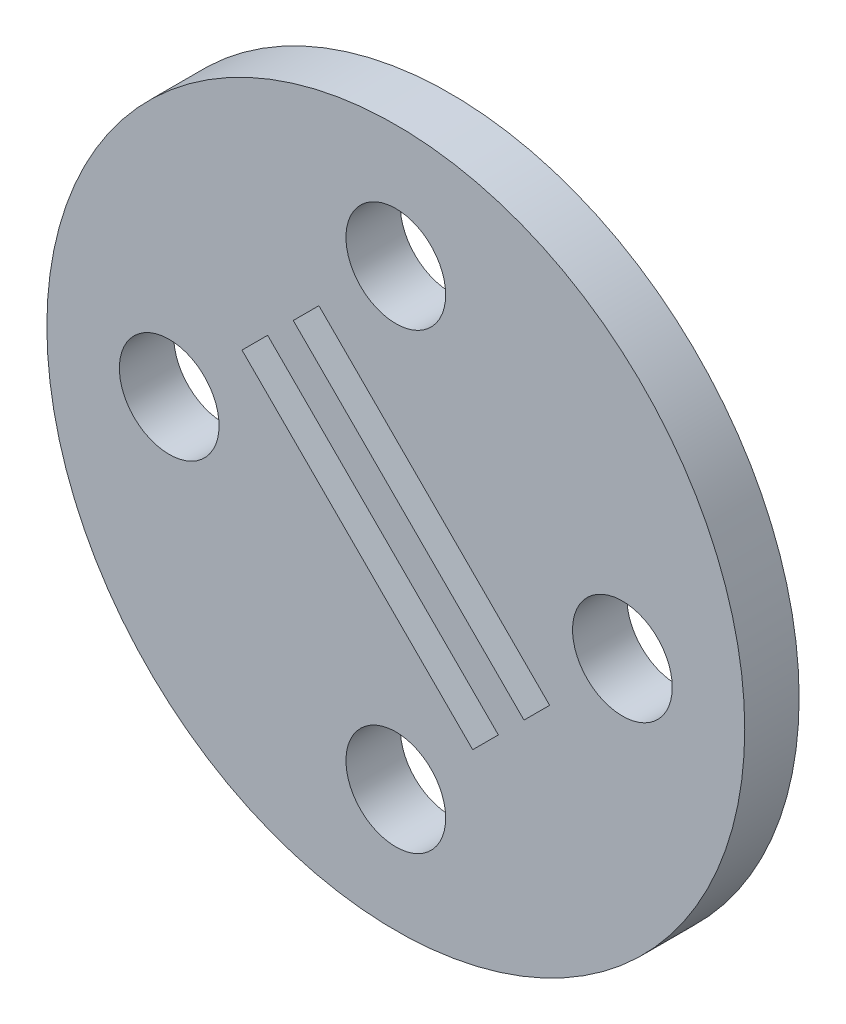
from build123d import *

# Parameters (mm, degrees)
MODEL_R             = 38.5
MODEL_R_2           = 5.5
BOSS_EXTRUDE1_DEPTH = 6


with BuildPart() as part:
    # Model → Boss-Extrude1 (new body)
    with BuildSketch(Plane.XY):
        Circle(MODEL_R)
        with Locations((-25, 0)):
            Circle(MODEL_R_2, mode=Mode.SUBTRACT)
        with Locations((0, 25)):
            Circle(MODEL_R_2, mode=Mode.SUBTRACT)
        with Locations((0, -25)):
            Circle(MODEL_R_2, mode=Mode.SUBTRACT)
        with Locations((25, 0)):
            Circle(MODEL_R_2, mode=Mode.SUBTRACT)
        Polygon((-16.970562748, 8.485281374), (-14.142135624, 11.313708499), (11.313708499, -14.142135624), (8.485281374, -16.970562748), align=None, mode=Mode.SUBTRACT)
        Polygon((-11.313708499, 14.142135624), (14.142135624, -11.313708499), (16.970562748, -8.485281374), (-8.485281374, 16.970562748), align=None, mode=Mode.SUBTRACT)
    extrude(amount=BOSS_EXTRUDE1_DEPTH)


solid = part.part
